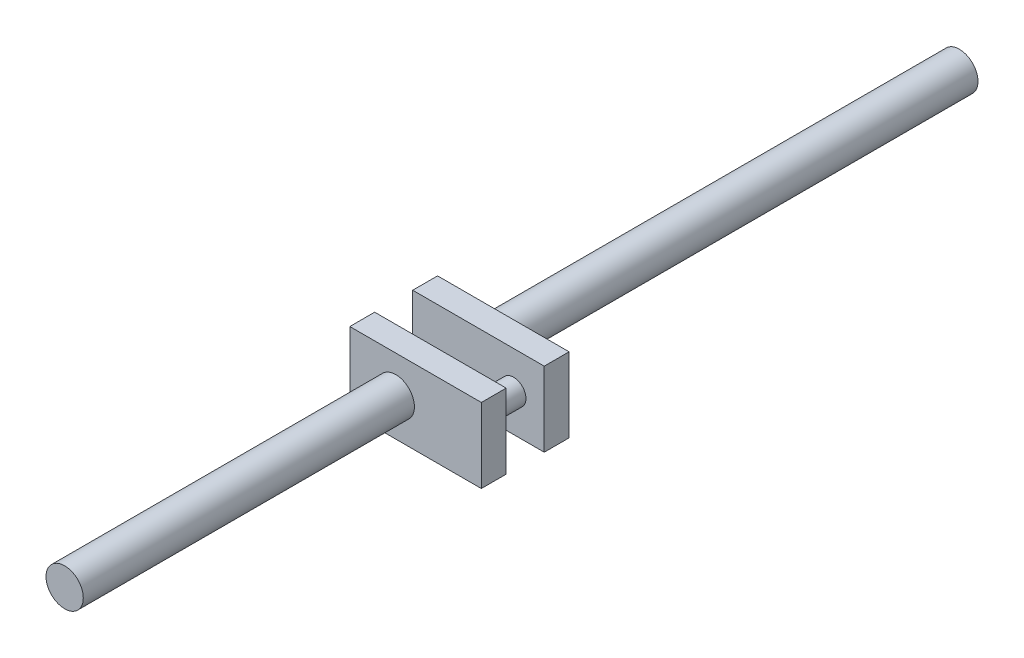
from build123d import *

# Parameters (mm, degrees)
SKETCH1_R           = 7.5
BOSS_EXTRUDE1_DEPTH = 180
SKETCH2_W           = 60
SKETCH2_H           = 25
CUT_EXTRUDE2_DEPTH  = 20
SKETCH3_W           = 52.918405924
SKETCH3_H           = 10
EXTRUDE_THIN1_DEPTH = 15
SKETCH4_R           = 5
BOSS_EXTRUDE2_DEPTH = 25


with BuildPart() as part:
    # Sketch1 → Boss-Extrude1 (new body, symmetric)
    with BuildSketch(Plane.XY):
        Circle(SKETCH1_R)
    extrude(amount=BOSS_EXTRUDE1_DEPTH, both=True)

    # Sketch2 → Cut-Extrude2 (cut, symmetric)
    with BuildSketch(Plane(origin=(0, 0, 0), x_dir=(1, 0, 0), z_dir=(0, 1, 0))):
        with Locations((14.409183819, -24.262804911)):
            Rectangle(SKETCH2_W, SKETCH2_H)
    extrude(amount=CUT_EXTRUDE2_DEPTH, both=True, mode=Mode.SUBTRACT)

    # Sketch3 → Extrude-Thin1 (add, symmetric)
    with BuildSketch(Plane(origin=(0, 0, 0), x_dir=(1, 0, 0), z_dir=(0, 1, 0))):
        with Locations((7.967689598, -16.457817956)):
            Rectangle(SKETCH3_W, SKETCH3_H)
        with Locations((7.967689598, -41.762804911)):
            Rectangle(SKETCH3_W, SKETCH3_H)
    extrude(amount=EXTRUDE_THIN1_DEPTH, both=True)

    # Sketch4 → Boss-Extrude2 (add)
    with BuildSketch(Plane.XY.offset(21.457817956)):
        with Locations((22.078448721, 0)):
            Circle(SKETCH4_R)
    extrude(amount=BOSS_EXTRUDE2_DEPTH)


solid = part.part
